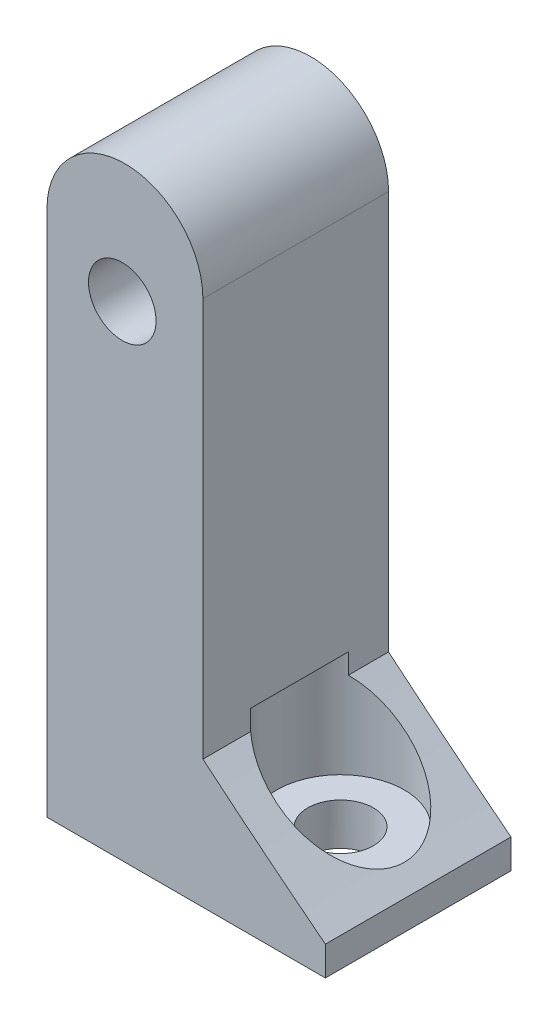
from build123d import *

# Parameters (mm, degrees)
SKETCH1_R           = 2.3114
BOSS_EXTRUDE1_DEPTH = 12.7
SKETCH2_R           = 2.3114
CUT_EXTRUDE1_DEPTH  = 12.7
SKETCH6_W           = 14.121517248
SKETCH6_H           = 29.833964346
CUT_EXTRUDE2_DEPTH  = 12.7
SKETCH7_W           = 28.687814756
SKETCH7_H           = 15.668419498
CUT_EXTRUDE3_DEPTH  = 12.7


with BuildPart() as part:
    # Sketch1 → Boss-Extrude1 (new body)
    with BuildSketch(Plane(origin=(0, 0, 287.67498399), x_dir=(-1, 0, 0), z_dir=(0, 0, -1))):
        with BuildLine():
            Line((-152.251778141, 257.179185564), (-150.258610496, 257.179185564))
            Line((-150.258610496, 257.179185564), (-150.258610494, 278.616785564))
            ThreePointArc((-150.258610494, 278.616785564), (-149.678330448, 280.017705521), (-148.277410491, 280.597985567))
            Line((-148.277410491, 280.597985567), (-136.390210491, 280.597985564))
            Line((-136.390210491, 280.597985564), (-136.390210491, 279.429585564))
            Line((-136.390210491, 279.429585564), (-148.277410491, 279.429585567))
            ThreePointArc((-148.277410491, 279.429585567), (-148.852146887, 279.19152196), (-149.090210496, 278.616785564))
            Line((-149.090210496, 278.616785564), (-149.090210494, 277.111994182))
            Line((-149.090210494, 277.111994182), (-129.232034093, 277.111994182))
            Line((-129.232034093, 277.111994182), (-129.232034093, 316.653648997))
            ThreePointArc((-129.232034093, 316.653648997), (-134.566034093, 321.987648997), (-139.900034093, 316.653648997))
            Line((-139.900034093, 316.653648997), (-139.900034093, 289.375013802))
            ThreePointArc((-139.900034093, 289.375013802), (-144.05701735, 285.950698605), (-148.277410489, 282.604846529))
            ThreePointArc((-148.277410489, 282.604846529), (-151.211817414, 281.317505148), (-152.251778141, 278.286585564))
            Line((-152.251778141, 278.286585564), (-152.251778141, 257.179185564))
        make_face()
        with Locations((-134.383610491, 313.727499576)):
            Circle(SKETCH1_R, mode=Mode.SUBTRACT)
    extrude(amount=BOSS_EXTRUDE1_DEPTH)

    # Sketch2 → Cut-Extrude1 (cut)
    with BuildSketch(Plane.ZY.offset(-150.25861052)):
        with Locations((281.230197131, 274.312688508)):
            Circle(SKETCH2_R)
        with Locations((281.230197131, 261.612688508)):
            Circle(SKETCH2_R)
    extrude(amount=-CUT_EXTRUDE1_DEPTH, mode=Mode.SUBTRACT)

    # Sketch5 → CBORE for #8 Button Head Cap Screw1 (revolve, cut)
    with BuildSketch(Plane(origin=(142.708000895, 290.757985564, 281.067357509), x_dir=(0, 0, 1), z_dir=(1, 0, 0))):
        Polygon((0, 0), (0, 33.5788), (2.2479, 33.5788), (2.2479, 7.2898), (4.36626, 7.2898), (4.36626, 0), align=None)
    revolve(axis=Axis((142.708000895, 297.107985564, 281.067357509), (0, -1, 0)), mode=Mode.SUBTRACT)

    # Sketch6 → Cut-Extrude2 (cut)
    with BuildSketch(Plane(origin=(0, 0, 274.97498399), x_dir=(-1, 0, 0), z_dir=(0, 0, -1))):
        with Locations((-155.338169113, 267.687864356)):
            Rectangle(SKETCH6_W, SKETCH6_H)
    extrude(amount=-CUT_EXTRUDE2_DEPTH, mode=Mode.SUBTRACT)

    # Sketch7 → Cut-Extrude3 (cut)
    with BuildSketch(Plane(origin=(0, 0, 274.97498399), x_dir=(-1, 0, 0), z_dir=(0, 0, -1))):
        with Locations((-133.933503111, 272.763775818)):
            Rectangle(SKETCH7_W, SKETCH7_H)
    extrude(amount=-CUT_EXTRUDE3_DEPTH, mode=Mode.SUBTRACT)


solid = part.part
